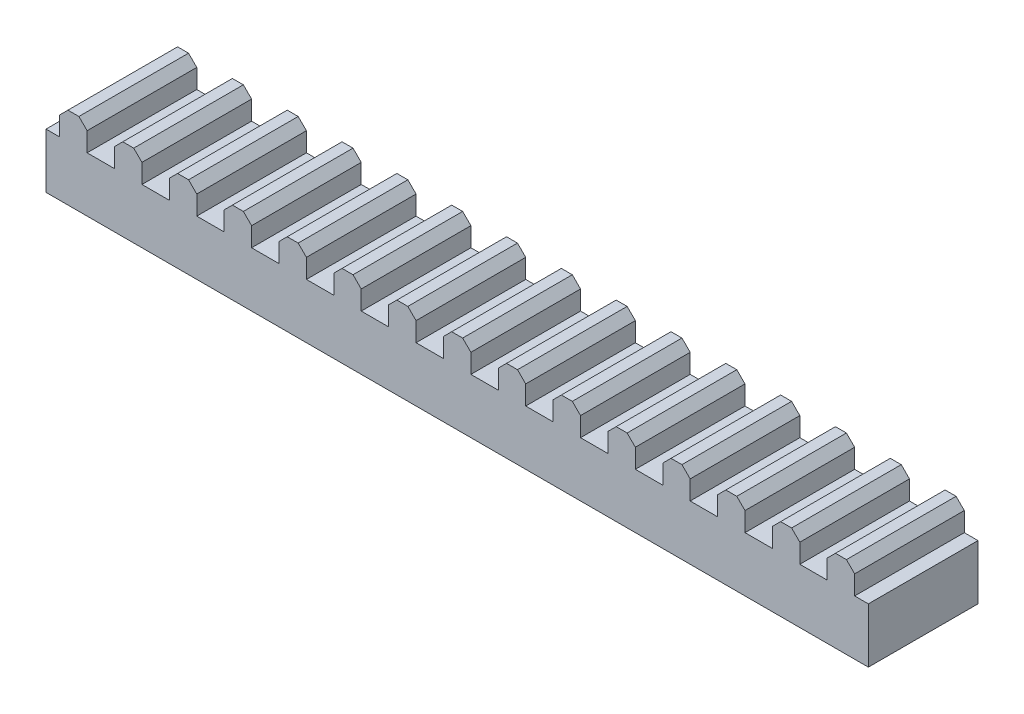
from build123d import *

# Parameters (mm, degrees)
SKETCH1_W           = 762
SKETCH1_H           = 50.8
BOSS_EXTRUDE1_DEPTH = 50.8
SKETCH2_W           = 25.4
SKETCH2_H           = 25.363561455
BOSS_EXTRUDE2_DEPTH = 101.6
CHAMFER1_SIZE       = 7.62


with BuildPart() as part:
    # Sketch1 → Boss-Extrude1 (new body, symmetric)
    with BuildSketch(Plane.XY):
        Rectangle(SKETCH1_W, SKETCH1_H)
    extrude(amount=BOSS_EXTRUDE1_DEPTH, both=True)

    # Sketch2 → Boss-Extrude2 (add, through all)
    with BuildSketch(Plane.XY.offset(50.8)):
        with Locations((-254, 38.081780728)):
            Rectangle(SKETCH2_W, SKETCH2_H)
        with Locations((355.6, 38.081780728)):
            Rectangle(SKETCH2_W, SKETCH2_H)
        with Locations((0, 38.081780728)):
            Rectangle(SKETCH2_W, SKETCH2_H)
        with Locations((50.8, 38.081780728)):
            Rectangle(SKETCH2_W, SKETCH2_H)
        with Locations((101.6, 38.081780728)):
            Rectangle(SKETCH2_W, SKETCH2_H)
        with Locations((152.4, 38.081780728)):
            Rectangle(SKETCH2_W, SKETCH2_H)
        with Locations((203.2, 38.081780728)):
            Rectangle(SKETCH2_W, SKETCH2_H)
        with Locations((254, 38.081780728)):
            Rectangle(SKETCH2_W, SKETCH2_H)
        with Locations((304.8, 38.081780728)):
            Rectangle(SKETCH2_W, SKETCH2_H)
        with Locations((-50.8, 38.081780728)):
            Rectangle(SKETCH2_W, SKETCH2_H)
        with Locations((-101.6, 38.081780728)):
            Rectangle(SKETCH2_W, SKETCH2_H)
        with Locations((-152.4, 38.081780728)):
            Rectangle(SKETCH2_W, SKETCH2_H)
        with Locations((-203.2, 38.081780728)):
            Rectangle(SKETCH2_W, SKETCH2_H)
        with Locations((-304.8, 38.081780728)):
            Rectangle(SKETCH2_W, SKETCH2_H)
        with Locations((-355.6, 38.081780728)):
            Rectangle(SKETCH2_W, SKETCH2_H)
    extrude(amount=-BOSS_EXTRUDE2_DEPTH)

    # Chamfer1
    chamfer1_edges = [part.edges().sort_by_distance(p)[0] for p in [
        (-368.3, 50.763561455, 0),
        (-317.5, 50.763561455, 0),
        (-266.7, 50.763561455, 0),
        (-215.9, 50.763561455, 0),
        (-165.1, 50.763561455, 0),
        (-114.3, 50.763561455, 0),
        (-63.5, 50.763561455, 0),
        (-12.7, 50.763561455, 0),
        (38.1, 50.763561455, 0),
        (88.9, 50.763561455, 0),
        (139.7, 50.763561455, 0),
        (190.5, 50.763561455, 0),
        (241.3, 50.763561455, 0),
        (292.1, 50.763561455, 0),
        (342.9, 50.763561455, 0),
        (368.3, 50.763561455, 0),
        (317.5, 50.763561455, 0),
        (266.7, 50.763561455, 0),
        (215.9, 50.763561455, 0),
        (165.1, 50.763561455, 0),
        (114.3, 50.763561455, 0),
        (63.5, 50.763561455, 0),
        (12.7, 50.763561455, 0),
        (-38.1, 50.763561455, 0),
        (-88.9, 50.763561455, 0),
        (-139.7, 50.763561455, 0),
        (-190.5, 50.763561455, 0),
        (-241.3, 50.763561455, 0),
        (-342.9, 50.763561455, 0),
        (-292.1, 50.763561455, 0),
    ]]
    chamfer(chamfer1_edges, length=CHAMFER1_SIZE)


solid = part.part
